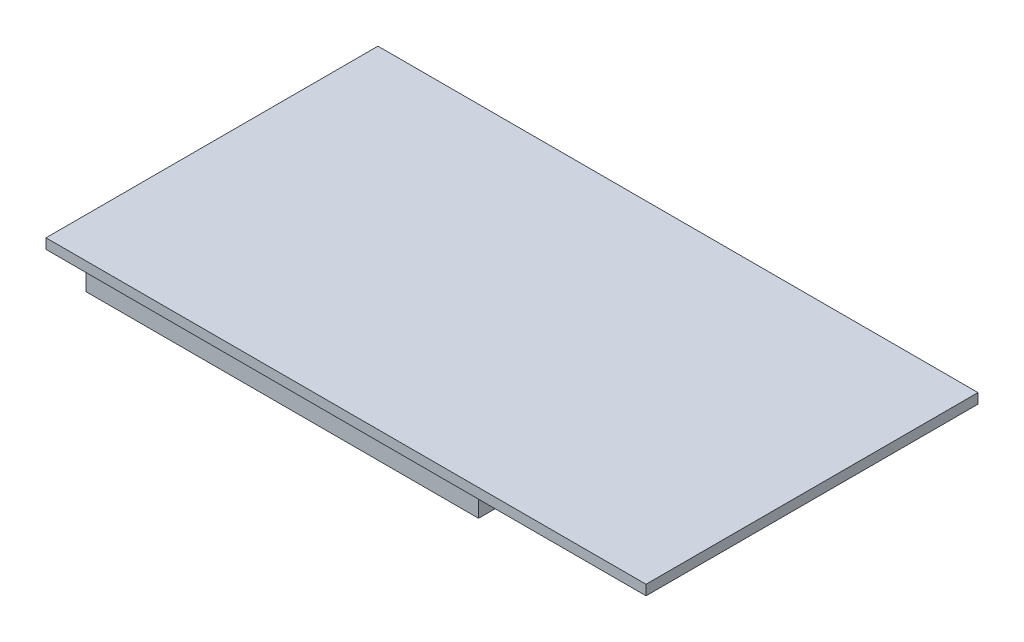
from build123d import *

# Parameters (mm, degrees)
SKETCH_1_W      = 119.3
SKETCH_1_H      = 66
EXTRUDE_1_DEPTH = 2
SKETCH_2_W      = 78
SKETCH_2_H      = 5
EXTRUDE_2_DEPTH = 10.3
SKETCH_3_W      = 7
SKETCH_3_H      = 3
SKETCH_3_W_2    = 6
SKETCH_3_H_2    = 2
EXTRUDE_3_DEPTH = 10


with BuildPart() as part:
    # Эскиз1 → Бобышка-Вытянуть1 (new body)
    with BuildSketch(Plane(origin=(0, 0, 0), x_dir=(1, 0, 0), z_dir=(0, 1, 0))):
        with Locations((59.65, 33)):
            Rectangle(SKETCH_1_W, SKETCH_1_H)
    extrude(amount=EXTRUDE_1_DEPTH)

    # Эскиз2 → Бобышка-Вытянуть2 (add)
    with BuildSketch(Plane.XZ):
        with Locations((40, -9.5)):
            Rectangle(SKETCH_2_W, SKETCH_2_H)
        with Locations((40, -56.5)):
            Rectangle(SKETCH_2_W, SKETCH_2_H)
    extrude(amount=EXTRUDE_2_DEPTH)

    # Эскиз3 → Бобышка-Вытянуть3 (add)
    with BuildSketch(Plane.ZY):
        with Locations((-33, -1.5)):
            Rectangle(SKETCH_3_W, SKETCH_3_H)
        with Locations((-33, -1.5)):
            Rectangle(SKETCH_3_W_2, SKETCH_3_H_2, mode=Mode.SUBTRACT)
    extrude(amount=-EXTRUDE_3_DEPTH)


solid = part.part
